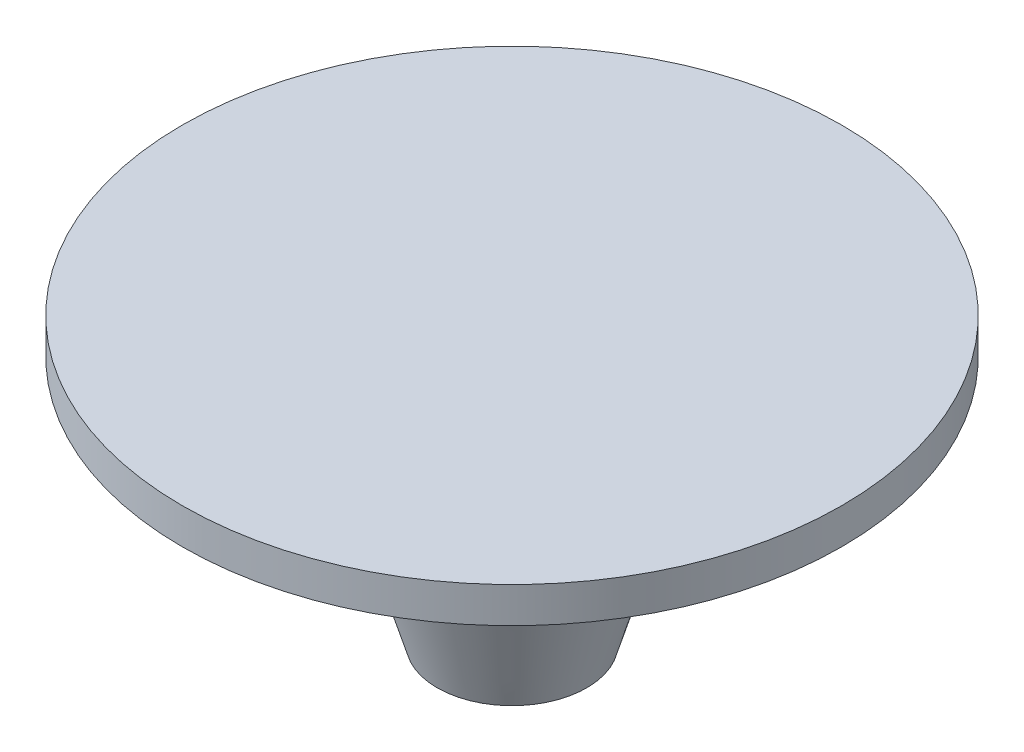
from build123d import *

# Parameters (mm, degrees)
FILLET1_R = 0.4


with BuildPart() as part:
    # Sketch1 → Revolve1 (revolve)
    with BuildSketch(Plane.XY):
        Polygon((0, 0), (-9.25, 0), (-9.25, -1), (-2.1, -1), (-2.1, -5), (-3, -5), (-2.1, -8), (0, -8), align=None)
    revolve(axis=Axis((0, 299.544827586, 0), (0, -1, 0)))

    # Fillet1
    fillet1_edges = [part.edges().sort_by_distance(p)[0] for p in [
        (2.1, -5, 0),
        (2.1, -1, 0),
    ]]
    fillet(fillet1_edges, radius=FILLET1_R)


solid = part.part
